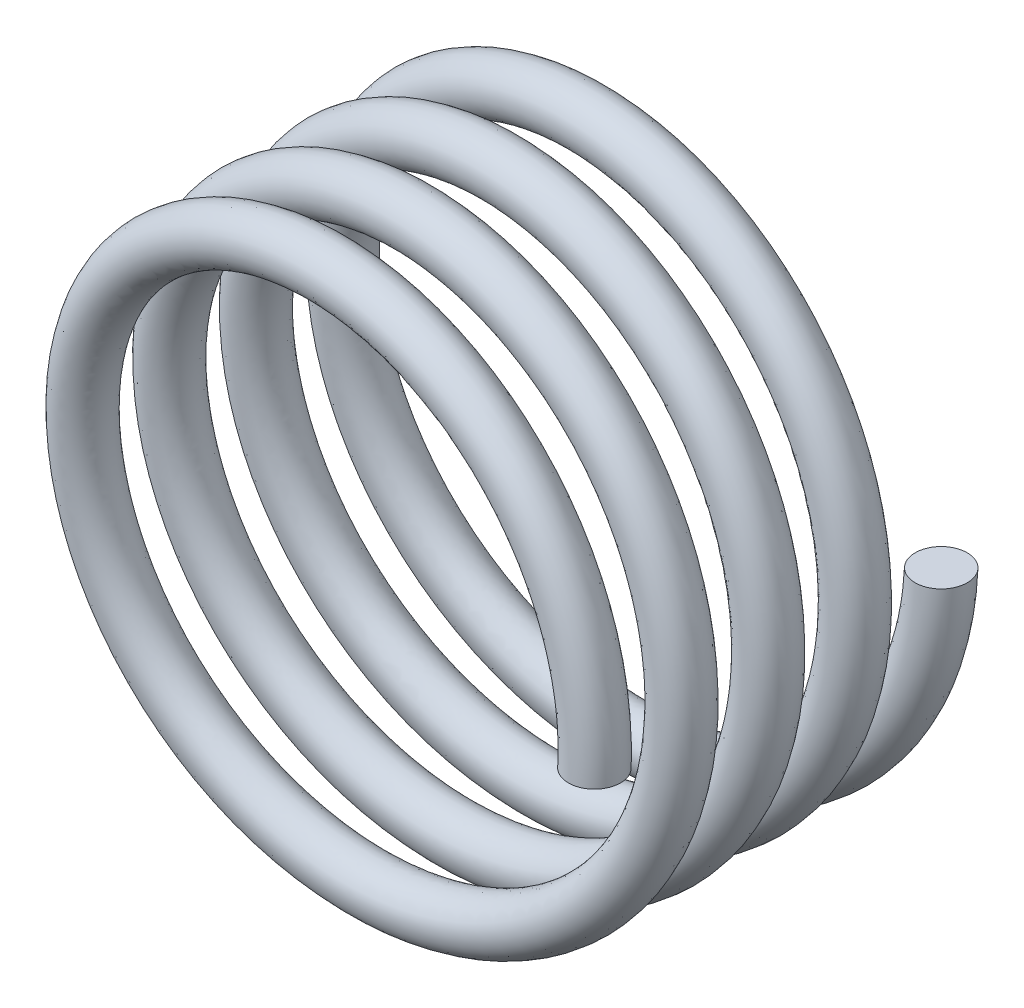
from build123d import *

# Parameters (mm, degrees)
BARRER7_PITCH  = 25
BARRER7_HEIGHT = 100
BARRER7_RADIUS = 80
CROQUIS3_R     = 7.5


with BuildPart() as part:
    # Barrer7: sweep along a helix
    with BuildLine() as barrer7_path:
        Helix(BARRER7_PITCH, BARRER7_HEIGHT, BARRER7_RADIUS, center=(0, 0, 0), direction=(0, 0, 1), lefthand=True)
    # Croquis3 → Barrer7 (sweep)
    with BuildSketch(Plane(origin=(0, 0, 0), x_dir=(1, 0, 0), z_dir=(0, 1, 0))):
        with Locations((80, 0)):
            Circle(CROQUIS3_R)
    sweep(path=barrer7_path.line, is_frenet=True)


solid = part.part
